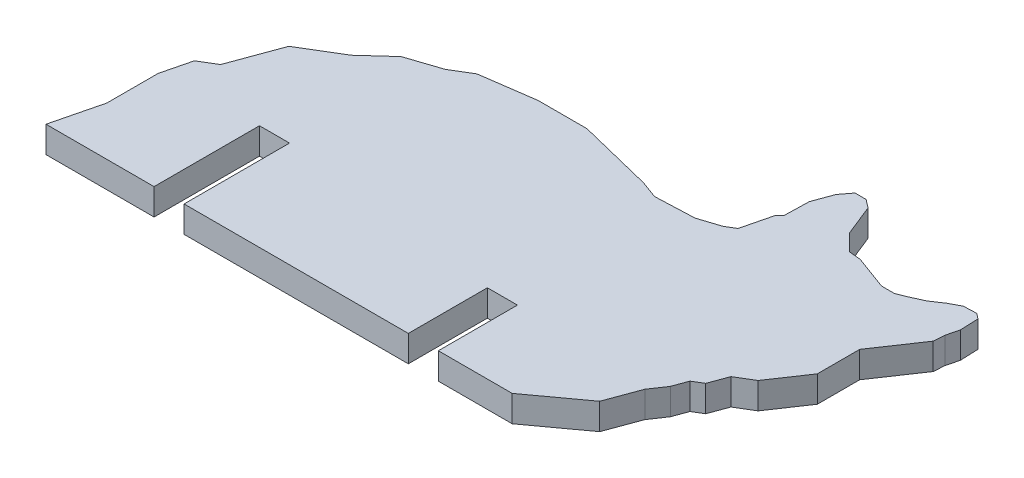
from build123d import *

# Parameters (mm, degrees)
BOSS_EXTRUDE4_DEPTH = 2.5
SKETCH3_W           = 2.85
SKETCH3_H           = 2.5
CUT_EXTRUDE1_DEPTH  = 10
SKETCH4_W           = 2.85
SKETCH4_H           = 2.5
CUT_EXTRUDE2_DEPTH  = 7.5


with BuildPart() as part:
    # Sketch2 → Boss-Extrude4 (new body)
    with BuildSketch(Plane(origin=(0, 0, 0), x_dir=(1, 0, 0), z_dir=(0, 1, 0))):
        Polygon((0, 0), (0.589412548, 2.381206373), (1.144861346, 4.62520037), (1.144861346, 9.49123355), (1.827568156, 12.249345527), (3.377711093, 13.184348171), (5.118763194, 17.917932427), (8.800884637, 20.138884573), (11.280786748, 22.394616205), (14.440798826, 23.447953565), (16.304846177, 24.572294527), (21.3928254, 25.291293944), (26.027509782, 25.291293944), (31.203392004, 24.010124046), (33.156993004, 23.526555316), (34.802606354, 22.921284885), (38.501454152, 23.073163176), (40.508590996, 23.727616723), (41.385127416, 24.256318851), (42.088080237, 27.096224014), (42.502286902, 27.510430679), (42.564029409, 29.84745559), (43.246427291, 31.702763579), (44.023704459, 32.719500007), (45.070889284, 32.719500007), (45.859589446, 32.116552566), (46.507843196, 30.50318738), (47.03069527, 29.201920191), (48.220652238, 28.011963224), (48.608289607, 27.624325855), (49.727600372, 27.510430679), (51.646333081, 26.804704651), (52.922878944, 26.335180347), (54.158394758, 26.335180347), (54.935057216, 26.647245064), (56.282727814, 27.252145785), (57.423923636, 28.011963224), (58.445785658, 28.559225004), (59.674350615, 28.609671077), (60.194070138, 28.212354617), (60.2647419, 26.491212706), (59.967729771, 25.291293944), (59.894673222, 24.256318851), (58.99338734, 22.921284885), (57.847567942, 21.224034494), (57.087511308, 20.098197019), (57.087511308, 16.074592048), (56.063262547, 14.557418737), (55.70254482, 14.023103901), (55.136298029, 13.184348171), (54.820686328, 12.716846849), (53.217353691, 11.749761674), (52.573042644, 9.998004432), (51.646333081, 9.439039274), (51.144861346, 8.07563452), (50.17002425, 6.631652471), (49.432034292, 4.62520037), (49.01935436, 3.503203372), (44.218024527, 0), align=None)
    extrude(amount=BOSS_EXTRUDE4_DEPTH)

    # Sketch3 → Cut-Extrude1 (cut)
    with BuildSketch(Plane.XY):
        with Locations((11.675, 1.25)):
            Rectangle(SKETCH3_W, SKETCH3_H)
    extrude(amount=-CUT_EXTRUDE1_DEPTH, mode=Mode.SUBTRACT)

    # Sketch4 → Cut-Extrude2 (cut)
    with BuildSketch(Plane.XY):
        with Locations((35.793024527, 1.25)):
            Rectangle(SKETCH4_W, SKETCH4_H)
    extrude(amount=-CUT_EXTRUDE2_DEPTH, mode=Mode.SUBTRACT)


solid = part.part
